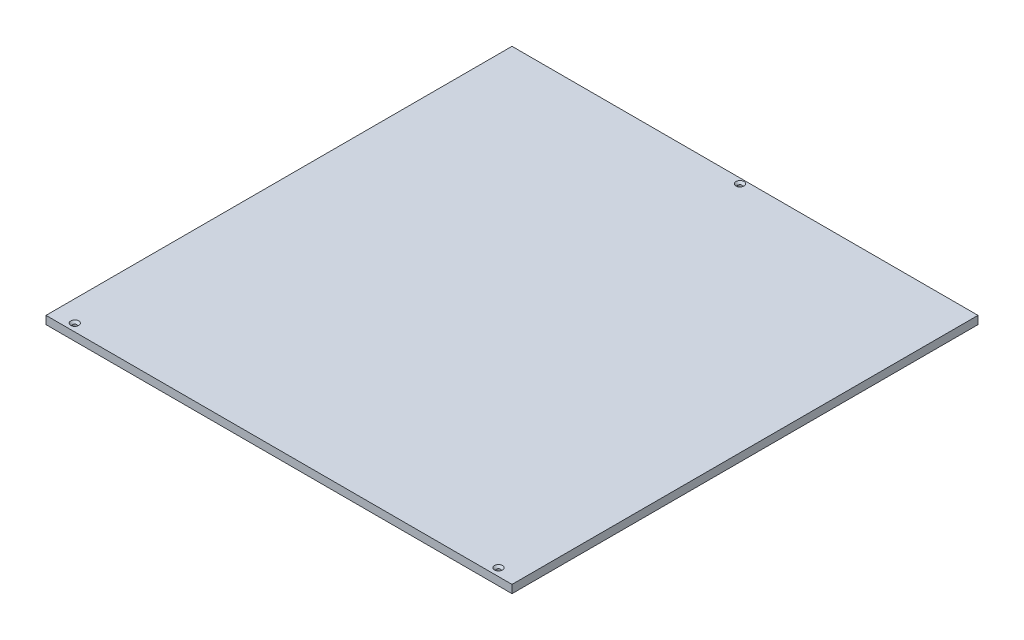
from build123d import *

# Parameters (mm, degrees)
SKETCH1_W                                       = 550
SKETCH1_H                                       = 550
SKETCH1_R                                       = 2.1
SKETCH1_W_2                                     = 10
SKETCH1_H_2                                     = 16
BOSS_EXTRUDE1_DEPTH                             = 9.525
CSK_FOR_M4_FLAT_HEAD_MACHINE_SCREW1_D           = 4.5
CSK_FOR_M4_FLAT_HEAD_MACHINE_SCREW1_DEPTH       = 9.53
CSK_FOR_M4_FLAT_HEAD_MACHINE_SCREW1_CSINK_D     = 9.4
CSK_FOR_M4_FLAT_HEAD_MACHINE_SCREW1_CSINK_ANGLE = 90
CSK_FOR_M4_FLAT_HEAD_MACHINE_SCREW1_TIP         = 1.351936393


with BuildPart() as part:
    # Sketch1 → Boss-Extrude1 (new body)
    with BuildSketch(Plane(origin=(0, 0, 0), x_dir=(1, 0, 0), z_dir=(0, 1, 0))):
        Rectangle(SKETCH1_W, SKETCH1_H)
        with Locations((0, 268.997567297)):
            Circle(SKETCH1_R, mode=Mode.SUBTRACT)
        with Locations((-250, -263)):
            Rectangle(SKETCH1_W_2, SKETCH1_H_2, mode=Mode.SUBTRACT)
        with Locations((250, -263)):
            Rectangle(SKETCH1_W_2, SKETCH1_H_2, mode=Mode.SUBTRACT)
        with Locations((-250, -263)):
            Rectangle(SKETCH1_W_2, SKETCH1_H_2)
        with Locations((-250, -266)):
            Circle(SKETCH1_R, mode=Mode.SUBTRACT)
        with Locations((250, -263)):
            Rectangle(SKETCH1_W_2, SKETCH1_H_2)
        with Locations((250, -266)):
            Circle(SKETCH1_R, mode=Mode.SUBTRACT)
    extrude(amount=BOSS_EXTRUDE1_DEPTH)

    # CSK for M4 Flat Head Machine Screw1
    with Locations(Plane(origin=(0, 9.525, 0), x_dir=(1, 0, 0), z_dir=(0, 1, 0))):
        with Locations((0, 268.997567297), (250, -266), (-250, -266)):
            CounterSinkHole(CSK_FOR_M4_FLAT_HEAD_MACHINE_SCREW1_D / 2, CSK_FOR_M4_FLAT_HEAD_MACHINE_SCREW1_CSINK_D / 2, depth=CSK_FOR_M4_FLAT_HEAD_MACHINE_SCREW1_DEPTH, counter_sink_angle=CSK_FOR_M4_FLAT_HEAD_MACHINE_SCREW1_CSINK_ANGLE)
            with Locations((0, 0, -(CSK_FOR_M4_FLAT_HEAD_MACHINE_SCREW1_DEPTH + CSK_FOR_M4_FLAT_HEAD_MACHINE_SCREW1_TIP / 2))):  # 118° drill point
                Cone(0, CSK_FOR_M4_FLAT_HEAD_MACHINE_SCREW1_D / 2, CSK_FOR_M4_FLAT_HEAD_MACHINE_SCREW1_TIP, mode=Mode.SUBTRACT)


solid = part.part
